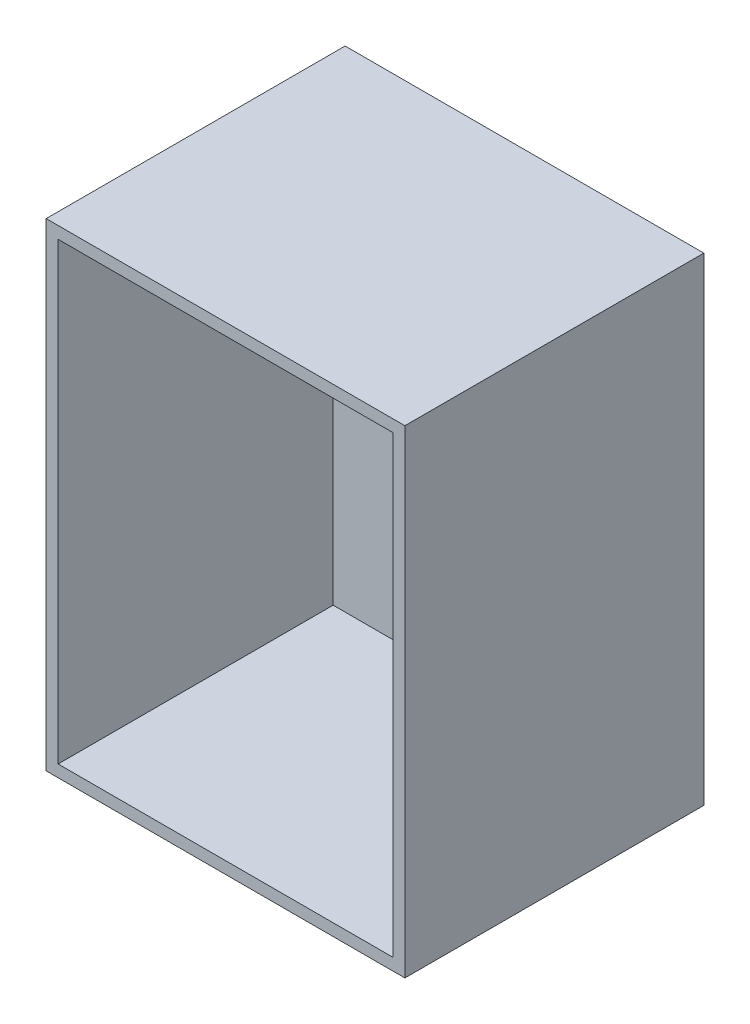
from build123d import *

# Parameters (mm, degrees)
SKETCH_1_W          = 30
SKETCH_1_H          = 40
EXTRUDE_1_DEPTH     = 25
SKETCH_2_W          = 28
SKETCH_2_H          = 38
CUT_EXTRUDE_1_DEPTH = 23


with BuildPart() as part:
    # 草图1 → 凸台-拉伸1 (new body)
    with BuildSketch(Plane.XY):
        with Locations((-2.12195122, -16.414634146)):
            Rectangle(SKETCH_1_W, SKETCH_1_H)
    extrude(amount=EXTRUDE_1_DEPTH)

    # 草图2 → 切除-拉伸1 (cut)
    with BuildSketch(Plane.XY.offset(25)):
        with Locations((-2.12195122, -16.414634146)):
            Rectangle(SKETCH_2_W, SKETCH_2_H)
    extrude(amount=-CUT_EXTRUDE_1_DEPTH, mode=Mode.SUBTRACT)


solid = part.part
